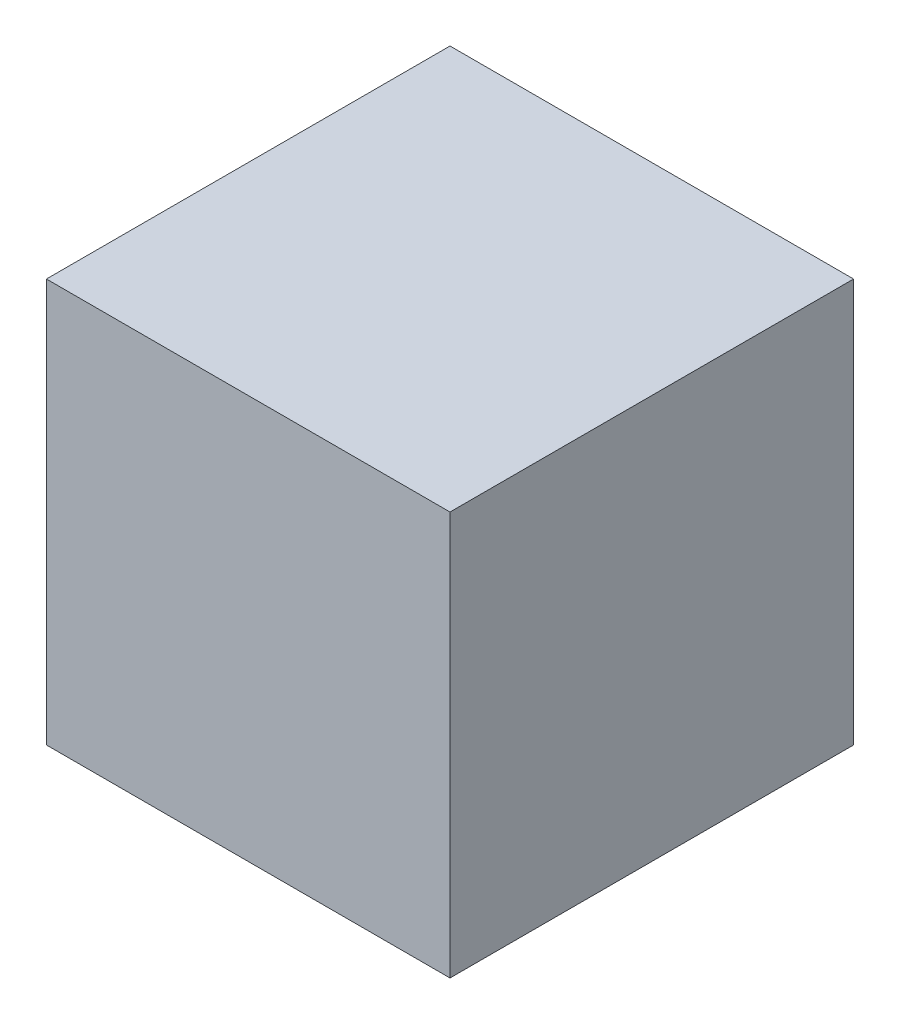
from build123d import *

# Parameters (mm, degrees)
SKETCH3_W  = 10
SKETCH3_H  = 10
CUBE_DEPTH = 10


with BuildPart() as part:
    # Sketch3 → Cube (new body)
    with BuildSketch(Plane(origin=(0, 30, 0), x_dir=(1, 0, 0), z_dir=(0, 1, 0))):
        with Locations((-5, -5)):
            Rectangle(SKETCH3_W, SKETCH3_H)
    extrude(amount=CUBE_DEPTH)


solid = part.part
